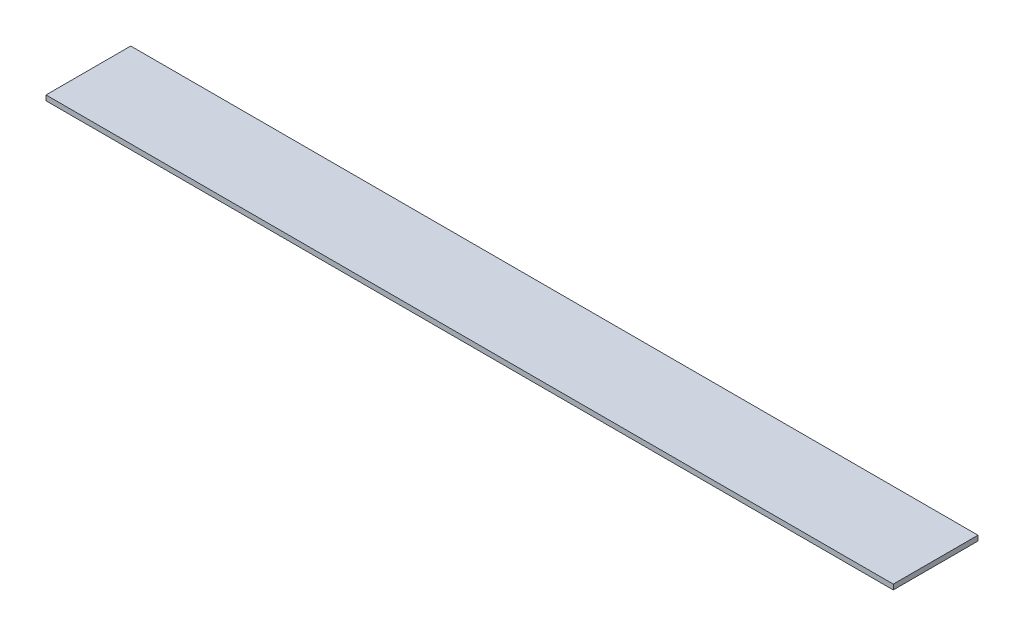
from build123d import *

# Parameters (mm, degrees)
SKETCH1_W           = 500
SKETCH1_H           = 50
BOSS_EXTRUDE1_DEPTH = 3


with BuildPart() as part:
    # Sketch1 → Boss-Extrude1 (new body)
    with BuildSketch(Plane(origin=(0, 0, 0), x_dir=(1, 0, 0), z_dir=(0, 1, 0))):
        Rectangle(SKETCH1_W, SKETCH1_H)
    extrude(amount=BOSS_EXTRUDE1_DEPTH)


solid = part.part
